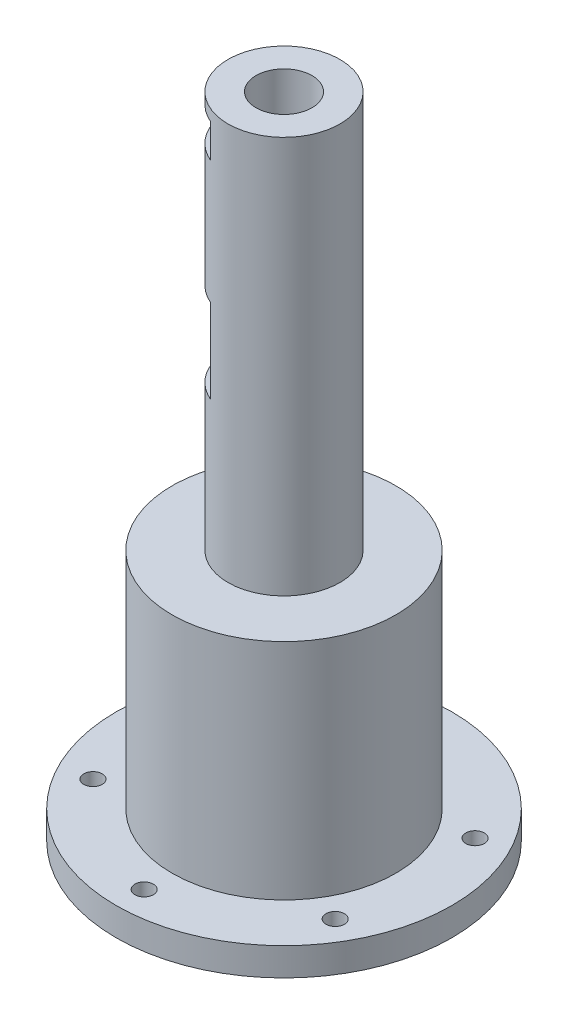
from build123d import *

# Parameters (mm, degrees)
SKETCH_1_R             = 30
EXTRUDE_1_DEPTH        = 5
SKETCH_2_R             = 20
EXTRUDE_2_DEPTH        = 40
SKETCH_5_R             = 10
EXTRUDE_3_DEPTH        = 71
CUT_EXTRUDE_2_REACH    = 118
SKETCH_6_R             = 5
SKETCH_7_W             = 15
SKETCH_7_H             = 15
CUT_EXTRUDE_3_DEPTH    = 2
SKETCH_8_W             = 15
SKETCH_8_H             = 15
CUT_EXTRUDE_4_DEPTH    = 2
HOLE_WIZARD_M4_2_D     = 3.3
HOLE_WIZARD_M4_2_DEPTH = 5
SKETCH_21_W            = 6
SKETCH_21_H            = 15
CUT_EXTRUDE_5_DEPTH    = 2
SKETCH_22_W            = 15
SKETCH_22_H            = 6
CUT_EXTRUDE_6_DEPTH    = 2


with BuildPart() as part:
    # 스케치1 → 보스-돌출1 (new body)
    with BuildSketch(Plane(origin=(0, 0, 0), x_dir=(1, 0, 0), z_dir=(0, 1, 0))):
        Circle(SKETCH_1_R)
    extrude(amount=EXTRUDE_1_DEPTH)

    # 스케치2 → 보스-돌출2 (add)
    with BuildSketch(Plane(origin=(0, 5, 0), x_dir=(1, 0, 0), z_dir=(0, 1, 0))):
        Circle(SKETCH_2_R)
    extrude(amount=EXTRUDE_2_DEPTH)

    # 스케치5 → 보스-돌출3 (add)
    with BuildSketch(Plane(origin=(0, 45, 0), x_dir=(1, 0, 0), z_dir=(0, 1, 0))):
        Circle(SKETCH_5_R)
    extrude(amount=EXTRUDE_3_DEPTH)

    # 스케치6 → 컷-돌출2 (cut, up to next)
    with BuildSketch(Plane(origin=(0, 116, 0), x_dir=(1, 0, 0), z_dir=(0, 1, 0)), mode=Mode.PRIVATE) as cut_extrude_2_sk1:
        Circle(SKETCH_6_R)
    cut_extrude_2_tool1 = extrude(cut_extrude_2_sk1.sketch, amount=-CUT_EXTRUDE_2_REACH, mode=Mode.PRIVATE) & part.part
    add(cut_extrude_2_tool1.solids().sort_by_distance((0, 116, 0))[0], mode=Mode.SUBTRACT)

    # 스케치7 → 컷-돌출3 (cut)
    with BuildSketch(Plane(origin=(0, 0, -10), x_dir=(-1, 0, 0), z_dir=(0, 0, -1))):
        with Locations((0, 78.5)):
            Rectangle(SKETCH_7_W, SKETCH_7_H)
    extrude(amount=-CUT_EXTRUDE_3_DEPTH, mode=Mode.SUBTRACT)

    # 스케치8 → 컷-돌출4 (cut)
    with BuildSketch(Plane(origin=(-8.660254038, 0, 5), x_dir=(0, -1, 0), z_dir=(-0.866025404, 0, 0.5))):
        with Locations((-78.5, 0)):
            Rectangle(SKETCH_8_W, SKETCH_8_H)
    extrude(amount=-CUT_EXTRUDE_4_DEPTH, mode=Mode.SUBTRACT)

    # M4 나사 구멍2
    with Locations(Plane(origin=(0, 5, 0), x_dir=(1, 0, 0), z_dir=(0, 1, 0))):
        with Locations((0, 25), (21.650635095, 12.5), (21.650635095, -12.5), (-21.650635095, 12.5), (-21.650635095, -12.5), (0, -25)):
            Hole(HOLE_WIZARD_M4_2_D / 2, depth=HOLE_WIZARD_M4_2_DEPTH)

    # 스케치21 → 컷-돌출5 (cut)
    with BuildSketch(Plane(origin=(-8.660254038, 0, 5), x_dir=(0, -1, 0), z_dir=(-0.866025404, 0, 0.5))):
        with Locations((-111, 0)):
            Rectangle(SKETCH_21_W, SKETCH_21_H)
    extrude(amount=-CUT_EXTRUDE_5_DEPTH, mode=Mode.SUBTRACT)

    # 스케치22 → 컷-돌출6 (cut)
    with BuildSketch(Plane(origin=(0, 0, -10), x_dir=(-1, 0, 0), z_dir=(0, 0, -1))):
        with Locations((0.623419069, 111)):
            Rectangle(SKETCH_22_W, SKETCH_22_H)
    extrude(amount=-CUT_EXTRUDE_6_DEPTH, mode=Mode.SUBTRACT)


solid = part.part
